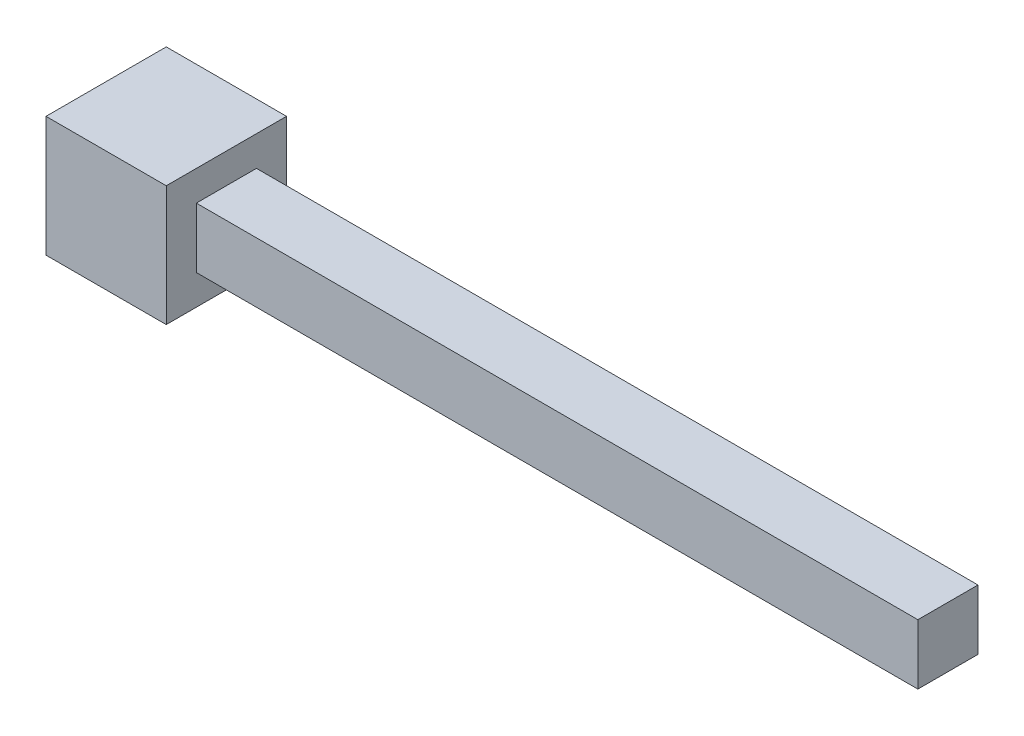
from build123d import *

# Parameters (mm, degrees)
SKETCH4_W           = 25.4
SKETCH4_H           = 25.4
BOSS_EXTRUDE1_DEPTH = 25.4
SKETCH5_W           = 12.7
SKETCH5_H           = 12.7
BOSS_EXTRUDE2_DEPTH = 152.4


with BuildPart() as part:
    # Sketch4 → Boss-Extrude1 (new body)
    with BuildSketch(Plane.XY):
        with Locations((-50.8, 1.603688601)):
            Rectangle(SKETCH4_W, SKETCH4_H)
    extrude(amount=BOSS_EXTRUDE1_DEPTH)

    # Sketch5 → Boss-Extrude2 (add)
    with BuildSketch(Plane(origin=(-38.1, 0, 0), x_dir=(0, 0, -1), z_dir=(1, 0, 0))):
        with Locations((-12.7, 1.603688601)):
            Rectangle(SKETCH5_W, SKETCH5_H)
    extrude(amount=BOSS_EXTRUDE2_DEPTH)


solid = part.part
